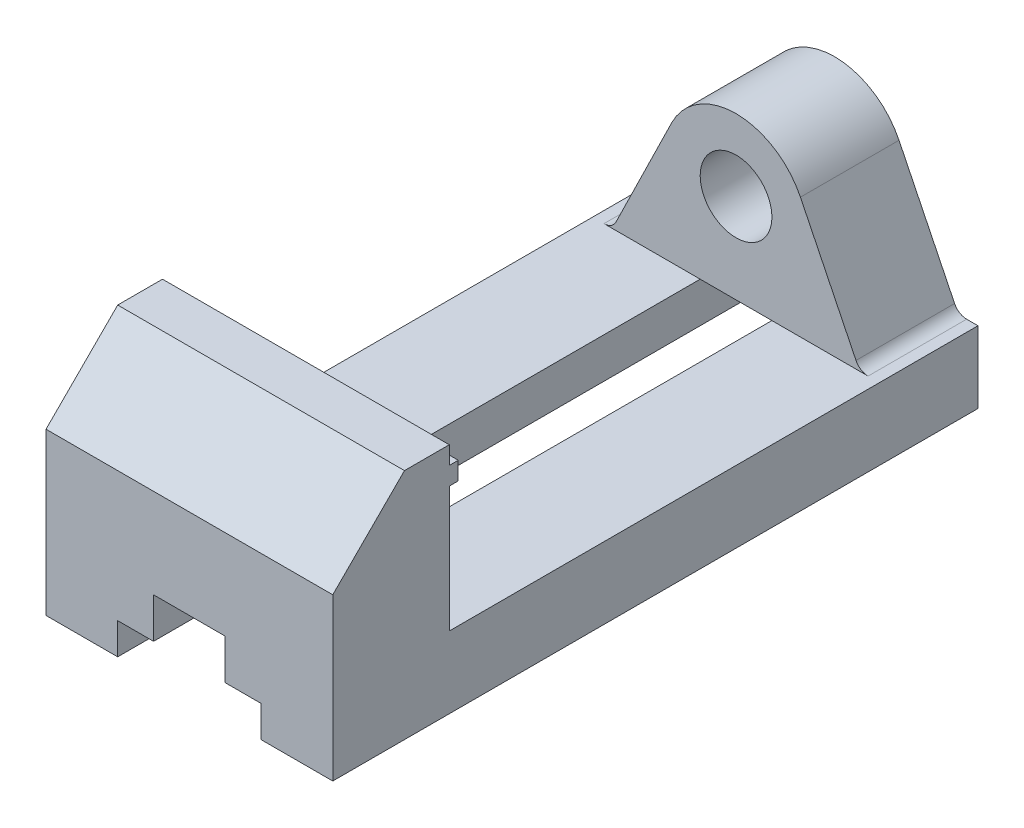
from build123d import *

# Parameters (mm, degrees)
BOSS_EXTRUDE1_DEPTH = 32
SKETCH2_R           = 3
CUT_EXTRUDE1_DEPTH  = 10
CHAMFER2_SIZE       = 3
CHAMFER3_SIZE       = 3
CHAMFER4_SIZE       = 3
CHAMFER5_SIZE       = 3
CUT_EXTRUDE3_DEPTH  = 145
CUT_EXTRUDE4_REACH  = 146
SKETCH7_R           = 8
CUT_EXTRUDE8_REACH  = 146
FILLET1_R           = 3
SKETCH9_W           = 64
SKETCH9_H           = 4
BOSS_EXTRUDE2_DEPTH = 2


with BuildPart() as part:
    # Sketch1 → Boss-Extrude1 (new body, symmetric)
    with BuildSketch(Plane(origin=(0, 0, 0), x_dir=(0, 0, -1), z_dir=(1, 0, 0))):
        Polygon((0, 0), (0, 36), (16, 52), (26, 52), (26, 16), (122, 16), (122, 52), (144, 52), (144, 0), align=None)
    extrude(amount=BOSS_EXTRUDE1_DEPTH, both=True)

    # Sketch2 → Cut-Extrude1 (cut)
    with BuildSketch(Plane(origin=(0, 0, 0), x_dir=(1, 0, 0), z_dir=(0, 1, 0))):
        with Locations((-22, 36)):
            Circle(SKETCH2_R)
        with Locations((22, 36)):
            Circle(SKETCH2_R)
        with Locations((-22, 106)):
            Circle(SKETCH2_R)
        with Locations((22, 106)):
            Circle(SKETCH2_R)
    extrude(amount=CUT_EXTRUDE1_DEPTH, mode=Mode.SUBTRACT)

    # Chamfer2
    chamfer2_edges = [part.edges().sort_by_distance(p)[0] for p in [
        (19, 10, -106),
    ]]
    chamfer(chamfer2_edges, length=CHAMFER2_SIZE)

    # Chamfer3
    chamfer3_edges = [part.edges().sort_by_distance(p)[0] for p in [
        (-25, 10, -106),
    ]]
    chamfer(chamfer3_edges, length=CHAMFER3_SIZE)

    # Chamfer4
    chamfer4_edges = [part.edges().sort_by_distance(p)[0] for p in [
        (19, 10, -36),
    ]]
    chamfer(chamfer4_edges, length=CHAMFER4_SIZE)

    # Chamfer5
    chamfer5_edges = [part.edges().sort_by_distance(p)[0] for p in [
        (-25, 10, -36),
    ]]
    chamfer(chamfer5_edges, length=CHAMFER5_SIZE)

    # Sketch6 → Cut-Extrude3 (cut, through all)
    with BuildSketch(Plane.XY):
        Polygon((-16, 0), (-16, 7), (-8, 7), (-8, 16), (0, 16), (8, 16), (8, 7), (16, 7), (16, 0), align=None)
    extrude(amount=-CUT_EXTRUDE3_DEPTH, mode=Mode.SUBTRACT)

    # Sketch7 → Cut-Extrude4 (cut, up to next)
    with BuildSketch(Plane(origin=(0, 0, -144), x_dir=(-1, 0, 0), z_dir=(0, 0, -1)), mode=Mode.PRIVATE) as cut_extrude4_sk1:
        with Locations((0, 36)):
            Circle(SKETCH7_R)
    cut_extrude4_tool1 = extrude(cut_extrude4_sk1.sketch, amount=-CUT_EXTRUDE4_REACH, mode=Mode.PRIVATE) & part.part
    add(cut_extrude4_tool1.solids().sort_by_distance((0, 36, -144))[0], mode=Mode.SUBTRACT)

    # Sketch8 → Cut-Extrude8 (cut, up to next)
    with BuildSketch(Plane(origin=(0, 0, -144), x_dir=(-1, 0, 0), z_dir=(0, 0, -1)), mode=Mode.PRIVATE) as cut_extrude8_sk1:
        with BuildLine():
            Line((-32, 16), (-27.596884244, 16))
            Line((-27.596884244, 16), (-14.372185951, 43.031377602))
            ThreePointArc((-14.372185951, 43.031377602), (-8.470476894, 49.573909576), (5.2e-08, 52))
            Line((5.2e-08, 52), (-32, 52))
            Line((-32, 52), (-32, 16))
        make_face()
    cut_extrude8_tool1 = extrude(cut_extrude8_sk1.sketch, amount=-CUT_EXTRUDE8_REACH, mode=Mode.PRIVATE) & part.part
    add(cut_extrude8_tool1.solids().sort_by_distance((23.880103, 38.416138, -144))[0], mode=Mode.SUBTRACT)
    # Sketch8 → Cut-Extrude8 (cut, up to next)
    with BuildSketch(Plane(origin=(0, 0, -144), x_dir=(-1, 0, 0), z_dir=(0, 0, -1)), mode=Mode.PRIVATE) as cut_extrude8_sk2:
        with BuildLine():
            Line((14.372185951, 43.031377602), (27.596884244, 16))
            Line((27.596884244, 16), (32, 16))
            Line((32, 16), (32, 52))
            Line((32, 52), (5.2e-08, 52))
            ThreePointArc((5.2e-08, 52), (8.470476938, 49.573909549), (14.372185951, 43.031377602))
        make_face()
    cut_extrude8_tool2 = extrude(cut_extrude8_sk2.sketch, amount=-CUT_EXTRUDE8_REACH, mode=Mode.PRIVATE) & part.part
    add(cut_extrude8_tool2.solids().sort_by_distance((-23.880103, 38.416138, -144))[0], mode=Mode.SUBTRACT)

    # Fillet1
    fillet1_edges = [part.edges().sort_by_distance(p)[0] for p in [
        (-27.596884244, 16, -133),
        (27.596884244, 16, -133),
    ]]
    fillet(fillet1_edges, radius=FILLET1_R)

    # Sketch9 → Boss-Extrude2 (add)
    with BuildSketch(Plane(origin=(0, 0, -26), x_dir=(-1, 0, 0), z_dir=(0, 0, -1))):
        with Locations((0, 46)):
            Rectangle(SKETCH9_W, SKETCH9_H)
    extrude(amount=BOSS_EXTRUDE2_DEPTH)


solid = part.part
